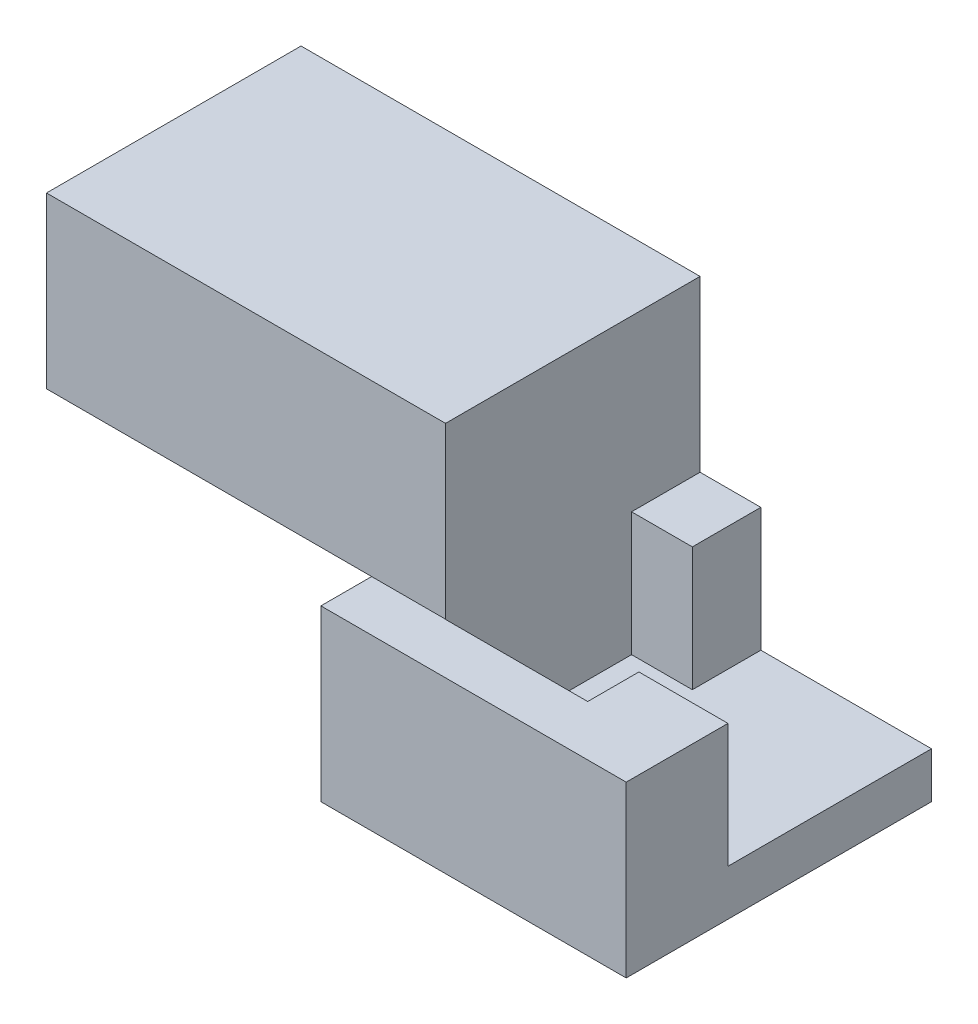
from build123d import *

# Parameters (mm, degrees)
SKETCH1_W           = 11.43
SKETCH1_H           = 11.43
BOSS_EXTRUDE1_DEPTH = 6.35
SKETCH3_W           = 6.389415989
SKETCH3_H           = 4.631950103
CUT_EXTRUDE1_DEPTH  = 7.62
SKETCH4_W           = 5.33014865
SKETCH4_H           = 6.972552684
CUT_EXTRUDE2_DEPTH  = 15.24
SKETCH5_W           = 14.938478928
SKETCH5_H           = 9.529491398
BOSS_EXTRUDE2_DEPTH = 6.35


with BuildPart() as part:
    # Sketch1 → Boss-Extrude1 (new body)
    with BuildSketch(Plane(origin=(0, 0, 0), x_dir=(1, 0, 0), z_dir=(0, 1, 0))):
        with Locations((5.715, 5.715)):
            Rectangle(SKETCH1_W, SKETCH1_H)
    extrude(amount=BOSS_EXTRUDE1_DEPTH)

    # Sketch3 → Cut-Extrude1 (cut)
    with BuildSketch(Plane(origin=(0, 0, -11.43), x_dir=(-1, 0, 0), z_dir=(0, 0, -1))):
        with Locations((-8.235292005, 4.034024949)):
            Rectangle(SKETCH3_W, SKETCH3_H)
    extrude(amount=-CUT_EXTRUDE1_DEPTH, mode=Mode.SUBTRACT)

    # Sketch4 → Cut-Extrude2 (cut)
    with BuildSketch(Plane(origin=(0, 1.718049897, 0), x_dir=(1, 0, 0), z_dir=(0, 1, 0))):
        with Locations((5.430693356, 5.379383443)):
            Rectangle(SKETCH4_W, SKETCH4_H)
    extrude(amount=CUT_EXTRUDE2_DEPTH, mode=Mode.SUBTRACT)

    # Sketch5 → Boss-Extrude2 (add)
    with BuildSketch(Plane(origin=(0, 6.35, 0), x_dir=(1, 0, 0), z_dir=(0, 1, 0))):
        with Locations((-4.703620433, 6.665254301)):
            Rectangle(SKETCH5_W, SKETCH5_H)
    extrude(amount=BOSS_EXTRUDE2_DEPTH)


solid = part.part
